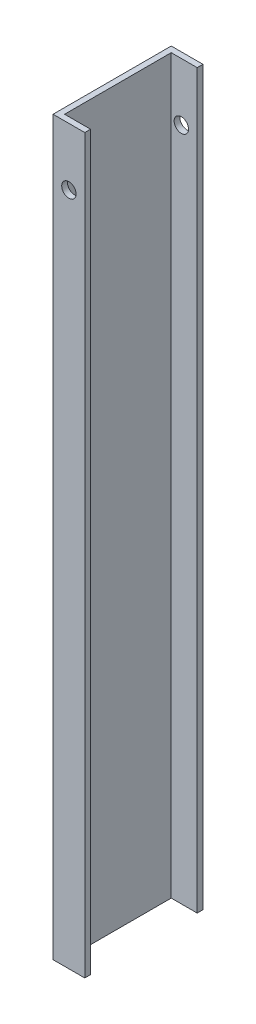
from build123d import *

# Parameters (mm, degrees)
BOSS_EXTRUDE1_DEPTH = 254
SKETCH2_R           = 2.5
CUT_EXTRUDE1_DEPTH  = 42


with BuildPart() as part:
    # Sketch1 → Boss-Extrude1 (new body)
    with BuildSketch(Plane(origin=(0, 0, 0), x_dir=(1, 0, 0), z_dir=(0, 1, 0))):
        Polygon((0, 0), (0, 41), (11, 41), (11, 39), (2, 39), (2, 2), (11, 2), (11, 0), align=None)
    extrude(amount=BOSS_EXTRUDE1_DEPTH)

    # Sketch2 → Cut-Extrude1 (cut, through all)
    with BuildSketch(Plane.XY):
        with Locations((5.5, 234)):
            Circle(SKETCH2_R)
    extrude(amount=-CUT_EXTRUDE1_DEPTH, mode=Mode.SUBTRACT)


solid = part.part
